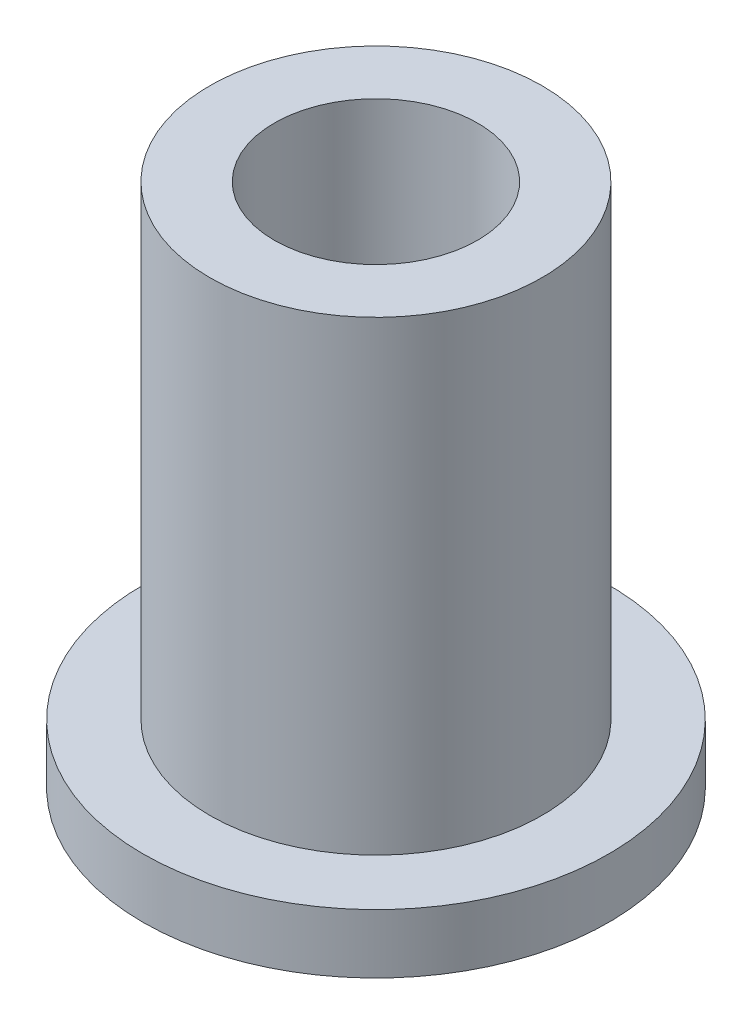
from build123d import *


with BuildPart() as part:
    # Sketch1 → Revolve1 (revolve)
    with BuildSketch(Plane(origin=(0, 0, 0), x_dir=(-1, 0, 0), z_dir=(0, 0, -1))):
        Polygon((-5.5, 0), (-2.6, 0), (-2.4, 0.2), (-2.4, 12.4), (-3.925, 12.4), (-3.925, 1.4), (-5.5, 1.4), align=None)
    revolve(axis=Axis((0, 0, 0), (0, 1, 0)))


solid = part.part
